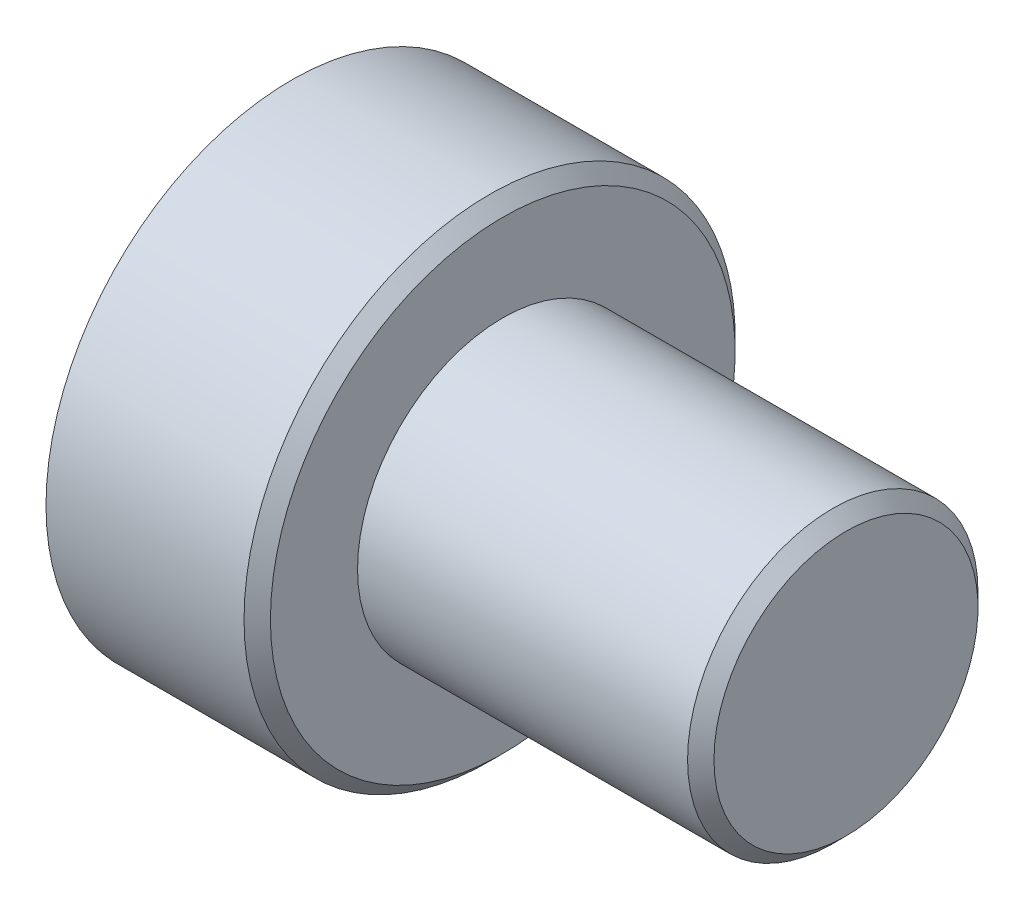
from build123d import *

# Parameters (mm, degrees)
CHAMFER1_SIZE = 0.127


with BuildPart() as part:
    # Sketch1 → Revolve1 (revolve)
    with BuildSketch(Plane.XY):
        Polygon((0, 1.8542), (0, 2.3622), (2.032, 2.3622), (2.032, 1.397), (5.334, 1.397), (5.334, 0), (1.905, 0), (1.524, 0.634090483), (1.524, 1.8542), align=None)
    revolve(axis=Axis((0, 0, 0), (1, 0, 0)))

    # Chamfer1
    chamfer1_edges = [part.edges().sort_by_distance(p)[0] for p in [
        (2.032, -2.3622, 0),
        (5.334, -1.397, 0),
    ]]
    chamfer(chamfer1_edges, length=CHAMFER1_SIZE)


solid = part.part
